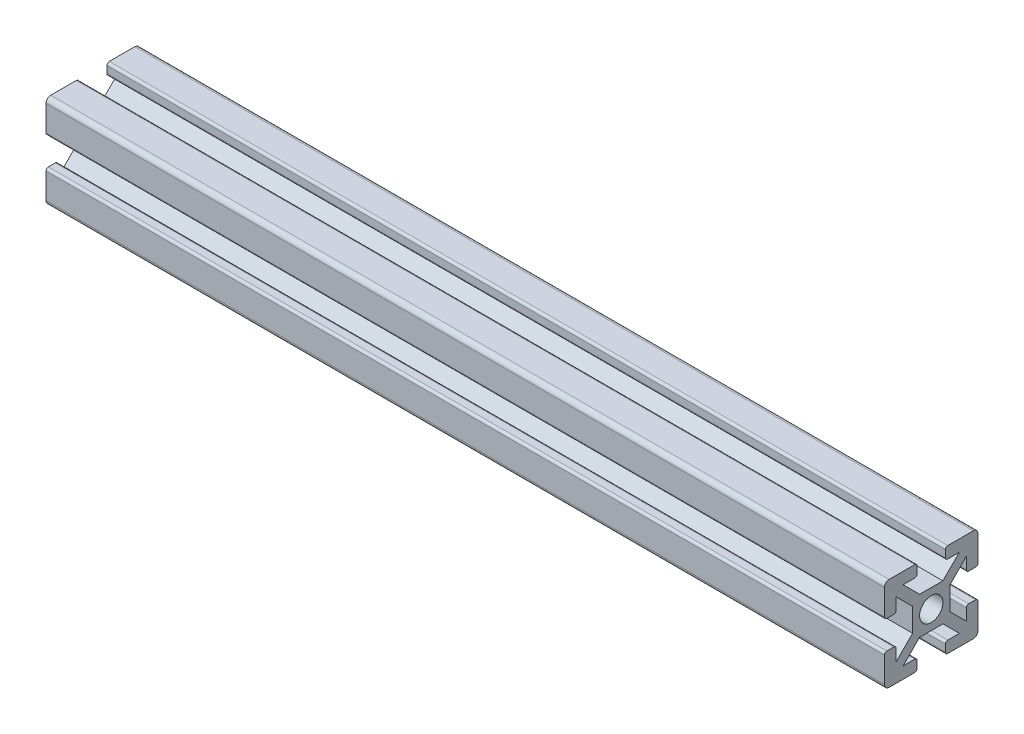
from build123d import *

# Parameters (mm, degrees)
SKETCH11_R                            = 2.5
ALUMINIUM_PROF_ALUMINIUM_PROF_1_DEPTH = 180


with BuildPart() as part:
    # Sketch11 → Aluminium prof ALUMINIUM PROF(1) (new body)
    with BuildSketch(Plane.YZ.offset(-81.593406593)):
        with BuildLine():
            Line((-2.5, 4), (2.5, 4))
            Line((2.5, 4), (6.035533906, 7.535533906))
            Line((6.035533906, 7.535533906), (3.535533906, 7.535533906))
            ThreePointArc((3.535533906, 7.535533906), (3.181980515, 7.681980515), (3.035533906, 8.035533906))
            Line((3.035533906, 8.035533906), (3.035533906, 9.535533906))
            ThreePointArc((3.035533906, 9.535533906), (3.181980515, 9.889087297), (3.535533906, 10.035533906))
            Line((3.535533906, 10.035533906), (9.035533906, 10.035533906))
            ThreePointArc((9.035533906, 10.035533906), (9.742640687, 9.742640687), (10.035533906, 9.035533906))
            Line((10.035533906, 9.035533906), (10.035533906, 3.535533906))
            ThreePointArc((10.035533906, 3.535533906), (9.889087297, 3.181980515), (9.535533906, 3.035533906))
            Line((9.535533906, 3.035533906), (8.035533906, 3.035533906))
            ThreePointArc((8.035533906, 3.035533906), (7.681980515, 3.181980515), (7.535533906, 3.535533906))
            Line((7.535533906, 3.535533906), (7.535533906, 6.035533906))
            Line((7.535533906, 6.035533906), (4, 2.5))
            Line((4, 2.5), (4, -2.5))
            Line((4, -2.5), (7.535533906, -6.035533906))
            Line((7.535533906, -6.035533906), (7.535533906, -3.535533906))
            ThreePointArc((7.535533906, -3.535533906), (7.681980515, -3.181980515), (8.035533906, -3.035533906))
            Line((8.035533906, -3.035533906), (9.535533906, -3.035533906))
            ThreePointArc((9.535533906, -3.035533906), (9.889087297, -3.181980515), (10.035533906, -3.535533906))
            Line((10.035533906, -3.535533906), (10.035533906, -9.035533906))
            ThreePointArc((10.035533906, -9.035533906), (9.742640687, -9.742640687), (9.035533906, -10.035533906))
            Line((9.035533906, -10.035533906), (3.535533906, -10.035533906))
            ThreePointArc((3.535533906, -10.035533906), (3.181980515, -9.889087297), (3.035533906, -9.535533906))
            Line((3.035533906, -9.535533906), (3.035533906, -8.035533906))
            ThreePointArc((3.035533906, -8.035533906), (3.181980515, -7.681980515), (3.535533906, -7.535533906))
            Line((3.535533906, -7.535533906), (6.035533906, -7.535533906))
            Line((6.035533906, -7.535533906), (2.5, -4))
            Line((2.5, -4), (-2.5, -4))
            Line((-2.5, -4), (-6.035533906, -7.535533906))
            Line((-6.035533906, -7.535533906), (-3.535533906, -7.535533906))
            ThreePointArc((-3.535533906, -7.535533906), (-3.181980515, -7.681980515), (-3.035533906, -8.035533906))
            Line((-3.035533906, -8.035533906), (-3.035533906, -9.535533906))
            ThreePointArc((-3.035533906, -9.535533906), (-3.181980515, -9.889087297), (-3.535533906, -10.035533906))
            Line((-3.535533906, -10.035533906), (-9.035533906, -10.035533906))
            ThreePointArc((-9.035533906, -10.035533906), (-9.742640687, -9.742640687), (-10.035533906, -9.035533906))
            Line((-10.035533906, -9.035533906), (-10.035533906, -3.535533906))
            ThreePointArc((-10.035533906, -3.535533906), (-9.889087297, -3.181980515), (-9.535533906, -3.035533906))
            Line((-9.535533906, -3.035533906), (-8.035533906, -3.035533906))
            ThreePointArc((-8.035533906, -3.035533906), (-7.681980515, -3.181980515), (-7.535533906, -3.535533906))
            Line((-7.535533906, -3.535533906), (-7.535533906, -6.035533906))
            Line((-7.535533906, -6.035533906), (-4, -2.5))
            Line((-4, -2.5), (-4, 2.5))
            Line((-4, 2.5), (-7.535533906, 6.035533906))
            Line((-7.535533906, 6.035533906), (-7.535533906, 3.535533906))
            ThreePointArc((-7.535533906, 3.535533906), (-7.681980515, 3.181980515), (-8.035533906, 3.035533906))
            Line((-8.035533906, 3.035533906), (-9.535533906, 3.035533906))
            ThreePointArc((-9.535533906, 3.035533906), (-9.889087297, 3.181980515), (-10.035533906, 3.535533906))
            Line((-10.035533906, 3.535533906), (-10.035533906, 9.035533906))
            ThreePointArc((-10.035533906, 9.035533906), (-9.742640687, 9.742640687), (-9.035533906, 10.035533906))
            Line((-9.035533906, 10.035533906), (-3.535533906, 10.035533906))
            ThreePointArc((-3.535533906, 10.035533906), (-3.181980515, 9.889087297), (-3.035533906, 9.535533906))
            Line((-3.035533906, 9.535533906), (-3.035533906, 8.035533906))
            ThreePointArc((-3.035533906, 8.035533906), (-3.181980515, 7.681980515), (-3.535533906, 7.535533906))
            Line((-3.535533906, 7.535533906), (-6.035533906, 7.535533906))
            Line((-6.035533906, 7.535533906), (-2.5, 4))
        make_face()
        Circle(SKETCH11_R, mode=Mode.SUBTRACT)
    extrude(amount=ALUMINIUM_PROF_ALUMINIUM_PROF_1_DEPTH)


solid = part.part
